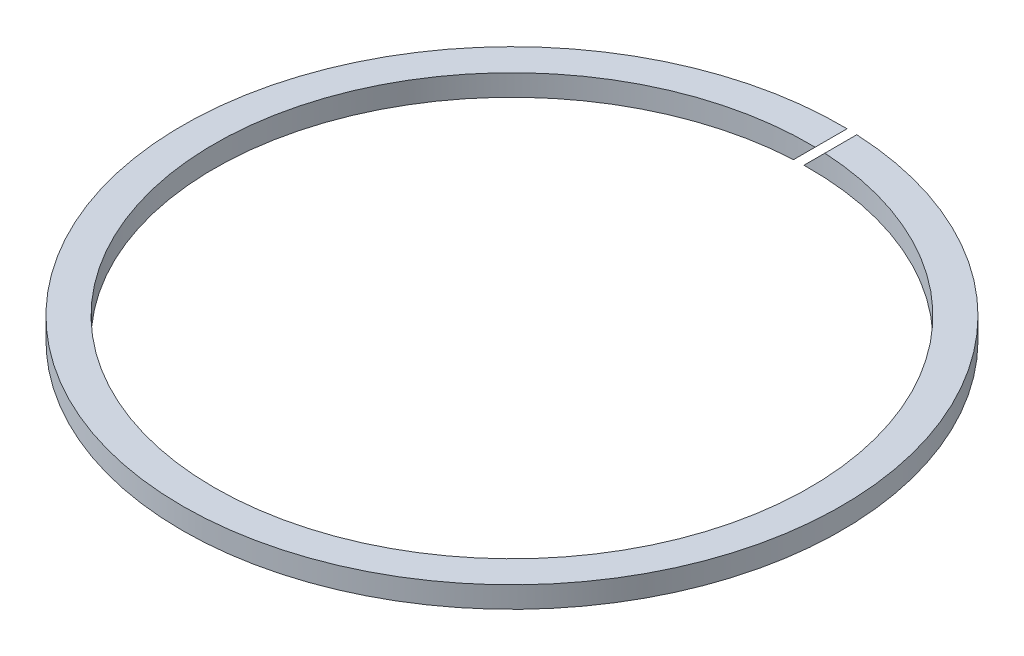
from build123d import *

# Parameters (mm, degrees)
SKETCH5_R           = 46.5
SKETCH5_R_2         = 42
BOSS_EXTRUDE3_DEPTH = 1.5
CUT_EXTRUDE3_DEPTH  = 66


with BuildPart() as part:
    # Sketch5 → Boss-Extrude3 (new body, symmetric)
    with BuildSketch(Plane(origin=(0, 0, 0), x_dir=(1, 0, 0), z_dir=(0, 1, 0))):
        Circle(SKETCH5_R)
        Circle(SKETCH5_R_2, mode=Mode.SUBTRACT)
    extrude(amount=BOSS_EXTRUDE3_DEPTH, both=True)

    # Sketch6 → Cut-Extrude3 (cut)
    with BuildSketch(Plane.XY):
        Polygon((-10.568822045, -11.275928826), (11.275928826, 10.568822045), (10.568822045, 11.275928826), (-11.275928826, -10.568822045), align=None)
    extrude(amount=-CUT_EXTRUDE3_DEPTH, mode=Mode.SUBTRACT)


solid = part.part
